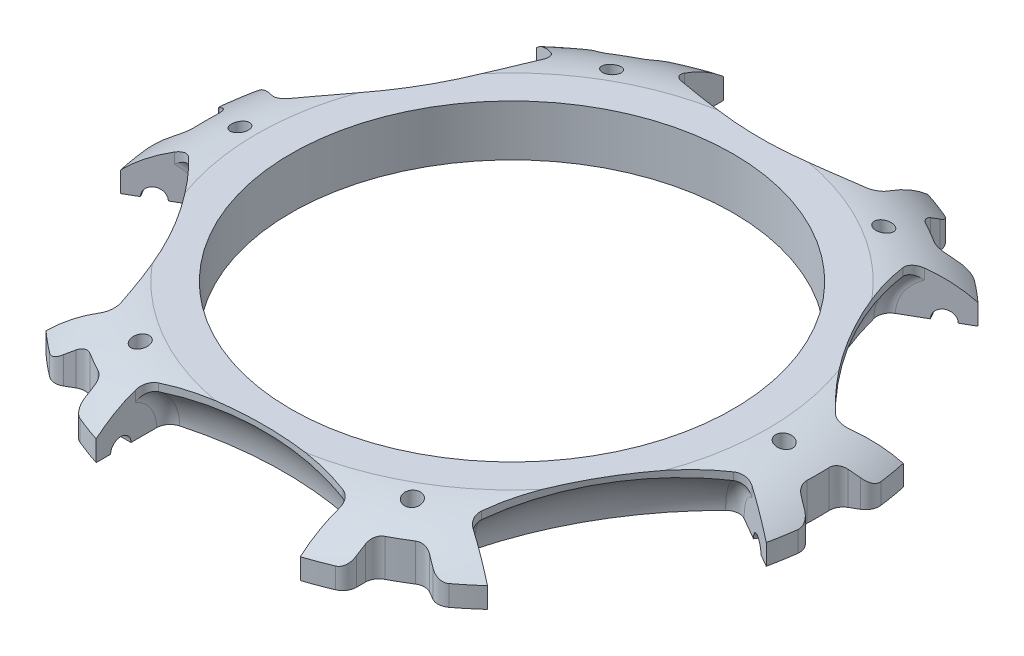
from build123d import *

# Parameters (mm, degrees)
SKETCH2_R           = 50
BOSS_EXTRUDE1_DEPTH = 7.5
CUT_EXTRUDE2_DEPTH  = 7.5
SKETCH5_R           = 1.5
CUT_EXTRUDE3_DEPTH  = 18
CIRPATTERN1_COUNT   = 6
CUT_EXTRUDE4_START  = -7.5
SKETCH6_R           = 50
CUT_EXTRUDE4_DEPTH  = 7.5
CUT_EXTRUDE5_REACH  = 9.5
SKETCH8_R           = 32.5
SKETCH9_R           = 1.25
CUT_EXTRUDE6_DEPTH  = 7.5
CIRPATTERN2_COUNT   = 6
FILLET1_R           = 2
FILLET2_R           = 2
FILLET3_R           = 2


with BuildPart() as part:
    # Sketch2 → Boss-Extrude1 (new body)
    with BuildSketch(Plane(origin=(0, 0, 0), x_dir=(1, 0, 0), z_dir=(0, 1, 0))):
        Circle(SKETCH2_R)
    extrude(amount=BOSS_EXTRUDE1_DEPTH)

    # Sketch3 → Cut-Revolve1 (revolve, cut)
    with BuildSketch(Plane(origin=(0, 0, 0), x_dir=(1, 0, 0), z_dir=(0, 1, 0))):
        with BuildLine():
            Line((-15, -42.5), (15, -42.5))
            Line((15, -42.5), (15, -35.732870999))
            ThreePointArc((15, -35.732870999), (0, -33.5), (-15, -35.732870999))
            Line((-15, -35.732870999), (-15, -42.5))
        make_face()
    cut_revolve1 = revolve(axis=Axis((-20.180044591, 0, 42.5), (1, 0, 0)), mode=Mode.SUBTRACT)

    # Sketch4 → Cut-Extrude2 (cut)
    with BuildSketch(Plane(origin=(0, 0, 0), x_dir=(1, 0, 0), z_dir=(0, 1, 0))):
        with BuildLine():
            Line((15, -38.877879494), (15, -47.696960071))
            ThreePointArc((15, -47.696960071), (0, -50), (-15, -47.696960071))
            Line((-15, -47.696960071), (-15, -38.877879494))
            ThreePointArc((-15, -38.877879494), (0, -36.5), (15, -38.877879494))
        make_face()
    cut_extrude2 = extrude(amount=CUT_EXTRUDE2_DEPTH, mode=Mode.SUBTRACT)

    # Sketch5 → Cut-Extrude3 (cut, symmetric)
    with BuildSketch(Plane(origin=(0, 0, 0), x_dir=(0, 0, -1), z_dir=(1, 0, 0))):
        with Locations((-42.5, 0)):
            Circle(SKETCH5_R)
    cut_extrude3 = extrude(amount=CUT_EXTRUDE3_DEPTH, both=True, mode=Mode.SUBTRACT)

    # CirPattern1: Cut-Revolve1, Cut-Extrude2, Cut-Extrude3 ×6 about axis
    cirpattern1_axis = Axis((0, 0, 0), (0, 1, 0))
    for i in range(1, CIRPATTERN1_COUNT):
        add(cut_revolve1.rotate(cirpattern1_axis, i * 360 / CIRPATTERN1_COUNT), mode=Mode.SUBTRACT)
        add(cut_extrude2.rotate(cirpattern1_axis, i * 360 / CIRPATTERN1_COUNT), mode=Mode.SUBTRACT)
        add(cut_extrude3.rotate(cirpattern1_axis, i * 360 / CIRPATTERN1_COUNT), mode=Mode.SUBTRACT)

    # Sketch6 → Cut-Extrude4 (cut)
    with BuildSketch(Plane.XZ.offset(CUT_EXTRUDE4_START)):
        Circle(SKETCH6_R)
        with BuildLine():
            Line((-28.264703056, 39.412644686), (-24.910600109, 37.476152446))
            ThreePointArc((-24.910600109, 37.476152446), (-22.5, 38.97114317), (-20, 40.311288741))
            Line((-20, 40.311288741), (-20, 44.18427322))
            ThreePointArc((-20, 44.18427322), (0, 48.5), (20, 44.18427322))
            Line((20, 44.18427322), (20, 40.311288741))
            ThreePointArc((20, 40.311288741), (22.5, 38.97114317), (24.910600109, 37.476152446))
            Line((24.910600109, 37.476152446), (28.264703056, 39.412644686))
            ThreePointArc((28.264703056, 39.412644686), (42.002232084, 24.25), (48.264703056, 4.771628534))
            Line((48.264703056, 4.771628534), (44.910600109, 2.835136295))
            ThreePointArc((44.910600109, 2.835136295), (45, 0), (44.910600109, -2.835136295))
            Line((44.910600109, -2.835136295), (48.264703056, -4.771628534))
            ThreePointArc((48.264703056, -4.771628534), (42.002232084, -24.25), (28.264703056, -39.412644686))
            Line((28.264703056, -39.412644686), (24.910600109, -37.476152446))
            ThreePointArc((24.910600109, -37.476152446), (22.5, -38.97114317), (20, -40.311288741))
            Line((20, -40.311288741), (20, -44.18427322))
            ThreePointArc((20, -44.18427322), (0, -48.5), (-20, -44.18427322))
            Line((-20, -44.18427322), (-20, -40.311288741))
            ThreePointArc((-20, -40.311288741), (-22.5, -38.97114317), (-24.910600109, -37.476152446))
            Line((-24.910600109, -37.476152446), (-28.264703056, -39.412644686))
            ThreePointArc((-28.264703056, -39.412644686), (-42.002232084, -24.25), (-48.264703056, -4.771628534))
            Line((-48.264703056, -4.771628534), (-44.910600109, -2.835136295))
            ThreePointArc((-44.910600109, -2.835136295), (-45, 0), (-44.910600109, 2.835136295))
            Line((-44.910600109, 2.835136295), (-48.264703056, 4.771628534))
            ThreePointArc((-48.264703056, 4.771628534), (-42.002232084, 24.25), (-28.264703056, 39.412644686))
        make_face(mode=Mode.SUBTRACT)
    extrude(amount=CUT_EXTRUDE4_DEPTH, mode=Mode.SUBTRACT)

    # Sketch8 → Cut-Extrude5 (cut, up to next)
    with BuildSketch(Plane.XZ, mode=Mode.PRIVATE) as cut_extrude5_sk1:
        Circle(SKETCH8_R)
    cut_extrude5_tool1 = extrude(cut_extrude5_sk1.sketch, amount=-CUT_EXTRUDE5_REACH, mode=Mode.PRIVATE) & part.part
    add(cut_extrude5_tool1.solids().sort_by_distance((0, 0, 0))[0], mode=Mode.SUBTRACT)

    # Sketch9 → Cut-Extrude6 (cut)
    with BuildSketch(Plane.XZ):
        with Locations((40, 0)):
            Circle(SKETCH9_R)
    cut_extrude6 = extrude(amount=-CUT_EXTRUDE6_DEPTH, mode=Mode.SUBTRACT)

    # CirPattern2: Cut-Extrude6 ×6 about axis
    cirpattern2_axis = Axis((0, 0, 0), (0, 1, 0))
    for i in range(1, CIRPATTERN2_COUNT):
        add(cut_extrude6.rotate(cirpattern2_axis, i * 360 / CIRPATTERN2_COUNT), mode=Mode.SUBTRACT)

    # Sketch7 → Cut-Revolve2 (revolve, cut)
    with BuildSketch(Plane.XY):
        with BuildLine():
            Line((-37.542025369, 7.5), (-50, 7.5))
            Line((-50, 7.5), (-50, 1.5))
            add(Edge.make_bspline(
                [(-50, 1.5), (-45.209417465, 6.974008424), (-37.542025369, 7.5)],
                knots=[0, 0, 0, 1, 1, 1], degree=2))
        make_face()
    revolve(axis=Axis((0, 0, 0), (0, 1, 0)), mode=Mode.SUBTRACT)

    # Fillet1
    fillet1_edges = [part.edges().sort_by_distance(p)[0] for p in [
        (-44.910600109, 2.740335666, -2.835136295),
        (-44.910600109, 2.740335666, 2.835136295),
        (-20, 2.740335666, -40.311288741),
        (-24.910600109, 2.740335666, -37.476152446),
        (24.910600109, 2.740335666, -37.476152446),
        (20, 2.740335666, -40.311288741),
        (44.910600109, 2.740335666, 2.835136295),
        (44.910600109, 2.740335666, -2.835136295),
        (24.910600109, 2.740335666, 37.476152446),
        (20, 2.740335666, 40.311288741),
        (-20, 2.740335666, 40.311288741),
        (-24.910600109, 2.740335666, 37.476152446),
    ]]
    fillet(fillet1_edges, radius=FILLET1_R)

    # Fillet2
    fillet2_edges = [part.edges().sort_by_distance(p)[0] for p in [
        (15, 3.262106543, 36.57102911),
        (-15, 3.262106543, 36.57102911),
        (-41.169231287, 6.258280336, 6.44855869),
        (-26.169231287, 6.258280336, 32.429320804),
        (-26.169231287, 6.258280336, -32.429320804),
        (-41.169231287, 6.258280336, -6.44855869),
        (15, 6.258280336, -38.877879494),
        (-15, 6.258280336, -38.877879494),
        (41.169231287, 6.258280336, -6.44855869),
        (26.169231287, 6.258280336, -32.429320804),
        (26.169231287, 6.258280336, 32.429320804),
        (41.169231287, 6.258280336, 6.44855869),
        (-15, 6.258280336, 38.877879494),
        (15, 6.258280336, 38.877879494),
        (39.171440251, 3.262106543, 5.295133498),
        (24.171440251, 3.262106543, 31.275895612),
        (24.171440251, 3.262106543, -31.275895612),
        (39.171440251, 3.262106543, -5.295133498),
        (-15, 3.262106543, -36.57102911),
        (15, 3.262106543, -36.57102911),
        (-39.171440251, 3.262106543, -5.295133498),
        (-24.171440251, 3.262106543, -31.275895612),
        (-24.171440251, 3.262106543, 31.275895612),
        (-39.171440251, 3.262106543, 5.295133498),
    ]]
    fillet(fillet2_edges, radius=FILLET2_R)

    # Fillet3
    fillet3_edges = [part.edges().sort_by_distance(p)[0] for p in [
        (-48.264703056, 1.514573795, 4.771628534),
        (-48.264703056, 1.514573795, -4.771628534),
        (-28.264703056, 1.514573795, -39.412644686),
        (-20, 1.514573795, -44.18427322),
        (20, 1.514573795, -44.18427322),
        (28.264703056, 1.514573795, -39.412644686),
        (48.264703056, 1.514573795, -4.771628534),
        (48.264703056, 1.514573795, 4.771628534),
        (20, 1.514573795, 44.18427322),
        (28.264703056, 1.514573795, 39.412644686),
        (-28.264703056, 1.514573795, 39.412644686),
        (-20, 1.514573795, 44.18427322),
    ]]
    fillet(fillet3_edges, radius=FILLET3_R)


solid = part.part
